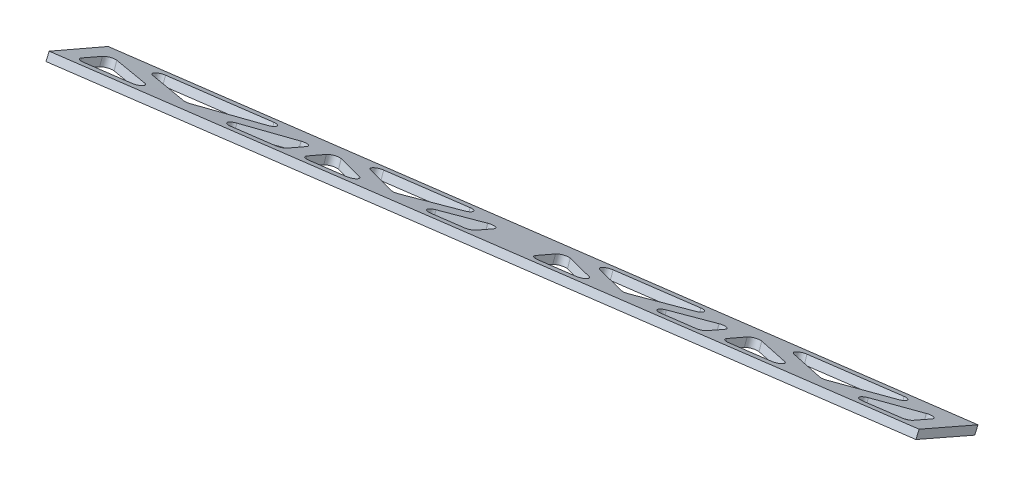
from build123d import *

# Parameters (mm, degrees)
CUT_EXTRUDE1_DEPTH      = 27.232069
CUT_EXTRUDE1_DEPTH_BACK = 30.502102
FILLET1_R               = 2.54


with BuildPart() as part:
    # Sketch1_5 → Loft4 section 0
    with BuildSketch(Plane(origin=(0, 0, 0), x_dir=(0, 0, -1), z_dir=(1, 0, 0))):
        Polygon((168.594796, -54.647515), (191.882473, -64.788723), (193.150124, -61.877763), (169.862447, -51.736556), align=None)
    # Sketch2_5 → Loft4 section 1
    with BuildSketch(Plane(origin=(-301.244, 0, 0), x_dir=(0, 0, -1), z_dir=(1, 0, 0))):
        Polygon((149.15773, -64.472266), (125.828369, -54.427321), (127.083987, -51.51115), (150.413348, -61.556096), align=None)
    loft()

    # Sketch3 → Cut-Extrude1 (cut, two sides)
    with BuildSketch(Plane(origin=(-1.131203, 18.632263, -8.11389), x_dir=(0.998454, 0.050955, -0.02219), z_dir=(-0.055577, 0.915421, -0.398643))) as cut_extrude1_sk:
        Polygon((-294.275324, 141.107563), (-294.241475, 156.716547), (-264.807097, 144.944118), align=None)
        Polygon((-251.17598, 146.718793), (-222.438598, 150.460198), (-222.438598, 165.683564), align=None)
        Polygon((-180.270209, 155.950225), (-156.928688, 158.989126), (-156.928688, 174.008873), align=None)
        Polygon((-287.785159, 160.973363), (-229.620948, 168.551806), (-258.719765, 149.348512), align=None)
        Polygon((-100.429934, 166.344865), (-76.767572, 169.425538), (-76.767572, 184.468386), align=None)
        Polygon((-5.217046, 193.888061), (-5.217046, 178.740912), (-31.139234, 175.366026), align=None)
        Polygon((-70.417572, 170.252263), (-70.417572, 185.808232), (-43.786545, 173.719435), align=None)
        Polygon((-136.674028, 161.62614), (-136.674028, 177.104861), (-112.318302, 164.797084), align=None)
        Polygon((-216.088598, 151.286923), (-216.088598, 166.746462), (-192.056074, 154.415788), align=None)
        Polygon((-210.542038, 171.037672), (-163.168101, 177.210208), (-186.855069, 158.884297), align=None)
        Polygon((-131.077414, 181.39143), (-83.059438, 187.64788), (-107.068426, 169.25887), align=None)
        Polygon((-64.449368, 190.072659), (-11.896276, 196.920008), (-38.172822, 178.144775), align=None)
    extrude(amount=CUT_EXTRUDE1_DEPTH, mode=Mode.SUBTRACT)
    extrude(cut_extrude1_sk.sketch, amount=-CUT_EXTRUDE1_DEPTH_BACK, mode=Mode.SUBTRACT)

    # Fillet1
    fillet1_edges = [part.edges().sort_by_distance(p)[0] for p in [
        (-294.858621, -54.234251, -130.289134),
        (-294.828325, -60.406912, -144.625899),
        (-265.436436, -54.256296, -134.464086),
        (-288.382769, -61.76463, -148.677581),
        (-259.359329, -55.691185, -138.643125),
        (-230.308598, -61.824309, -156.917442),
        (-251.826618, -54.266492, -136.395294),
        (-223.136721, -60.323506, -154.442596),
        (-223.134137, -54.287988, -140.466704),
        (-216.794058, -54.292738, -141.36635),
        (-192.799084, -54.310712, -144.771193),
        (-216.796608, -60.423118, -155.558526),
        (-211.259222, -61.843885, -159.620265),
        (-163.958622, -61.892495, -166.331516),
        (-187.606747, -55.819434, -148.98801),
        (-181.031634, -54.319527, -146.440973),
        (-157.728386, -60.304085, -163.531515),
        (-157.726584, -54.336984, -149.747918),
        (-113.1859, -54.370344, -156.068162),
        (-137.50357, -54.352131, -152.617527),
        (-137.50519, -60.505497, -166.820616),
        (-131.917612, -61.925424, -170.877658),
        (-107.944537, -55.877679, -160.27825),
        (-83.973968, -61.974697, -177.680146),
        (-101.316107, -54.379233, -157.752465),
        (-77.690717, -54.396926, -161.104867),
        (-77.691606, -60.388291, -174.903095),
        (-71.350639, -54.401674, -162.004514),
        (-44.761222, -54.421585, -165.777507),
        (-71.351483, -60.598644, -176.272868),
        (-65.392707, -61.993794, -180.31655),
        (-12.920968, -62.047722, -187.761507),
        (-39.15638, -55.899025, -169.960861),
        (-32.133672, -54.43104, -167.569335),
        (-6.25206, -60.496885, -185.129897),
        (-6.251987, -54.450419, -171.241903),
    ]]
    fillet(fillet1_edges, radius=FILLET1_R)


solid = part.part
